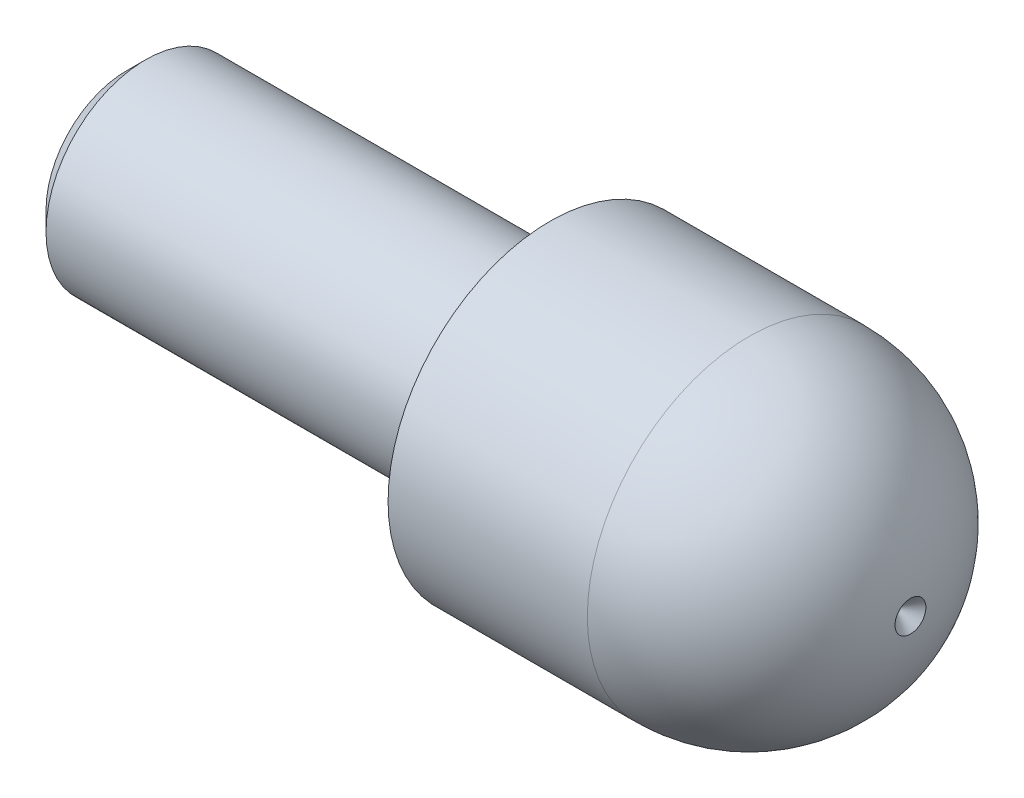
from build123d import *


with BuildPart() as part:
    # Sketch1 → Revolve1 (revolve)
    with BuildSketch(Plane.XY):
        Polygon((-17, 0), (-17, 3.233), (-16.233, 4), (0, 4), (0, 0), align=None)
    revolve(axis=Axis((0, 0, 0), (-1, 0, 0)))

    # Sketch2 → Revolve2 (revolve)
    with BuildSketch(Plane.XY):
        with BuildLine():
            Line((0, 0), (0, 6.5))
            Line((0, 6.5), (8, 6.5))
            ThreePointArc((8, 6.5), (12.371375393, 4.81051735), (14.470331437, 0.620331437))
            Line((14.470331437, 0.620331437), (13.85, 0))
            Line((13.85, 0), (0, 0))
        make_face()
    revolve(axis=Axis((50, 0, 0), (-1, 0, 0)))

    # Sketch3 → Cut-Revolve1 (revolve, cut)
    with BuildSketch(Plane.XY):
        with BuildLine():
            Line((-0.826794919, 3.9), (-0.173205081, 3.9))
            ThreePointArc((-0.173205081, 3.9), (-0.073205081, 3.926794919), (0, 4))
            Line((0, 4), (0, 4.9))
            Line((0, 4.9), (-1, 4.9))
            Line((-1, 4.9), (-1, 4))
            ThreePointArc((-1, 4), (-0.926794919, 3.926794919), (-0.826794919, 3.9))
        make_face()
    revolve(axis=Axis((0, 0, 0), (-1, 0, 0)), mode=Mode.SUBTRACT)


solid = part.part
